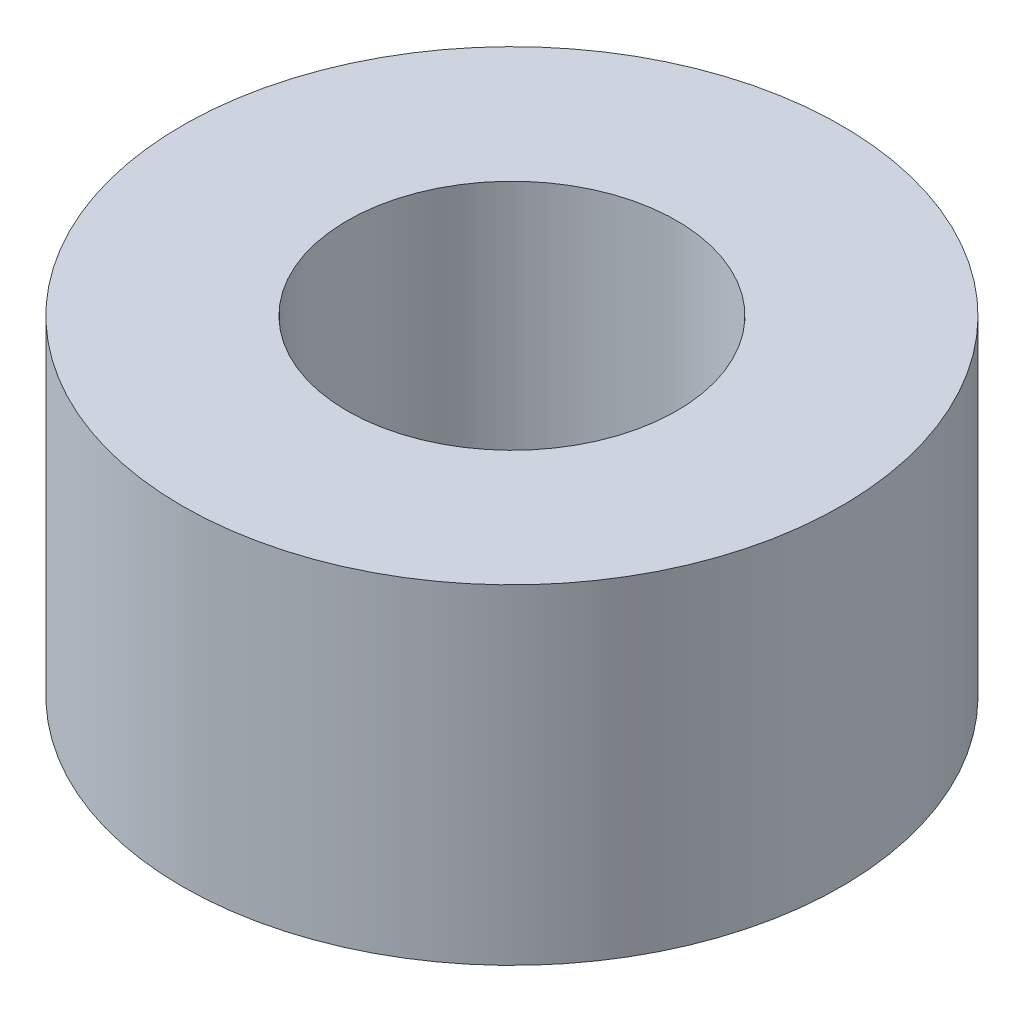
from build123d import *

# Parameters (mm, degrees)
SKETCH1_R           = 2
SKETCH1_R_2         = 1
BOSS_EXTRUDE1_DEPTH = 2


with BuildPart() as part:
    # Sketch1 → Boss-Extrude1 (new body)
    with BuildSketch(Plane(origin=(0, 0, 0), x_dir=(1, 0, 0), z_dir=(0, 1, 0))):
        Circle(SKETCH1_R)
        Circle(SKETCH1_R_2, mode=Mode.SUBTRACT)
    extrude(amount=BOSS_EXTRUDE1_DEPTH)


solid = part.part
